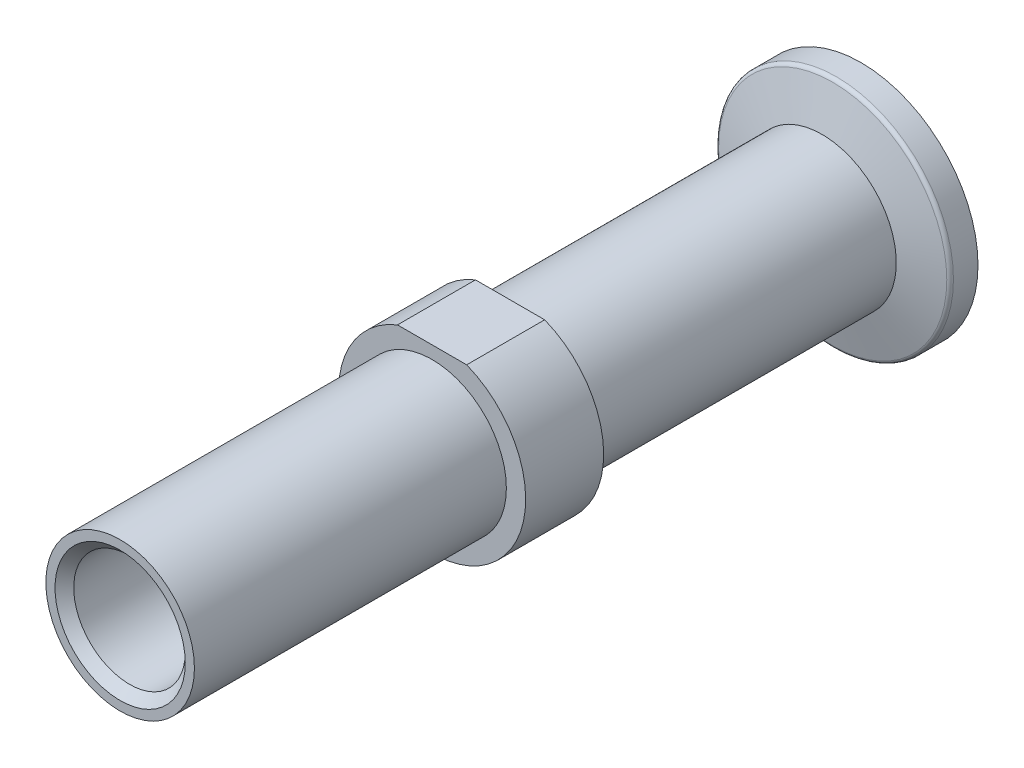
from build123d import *

# Parameters (mm, degrees)
SKETCH1_R           = 12
BOSS_EXTRUDE1_DEPTH = 90
SKETCH3_OUTSIDE_W   = 45.238
SKETCH3_OUTSIDE_H   = 45.238
SKETCH3_OUTSIDE_R   = 9.525
CUT_EXTRUDE1_DEPTH  = 40
SKETCH4_OUTSIDE_W   = 45.238
SKETCH4_OUTSIDE_H   = 45.238
SKETCH4_OUTSIDE_R   = 9.525
CUT_EXTRUDE2_DEPTH  = 40
SKETCH6_R           = 7.15
CUT_EXTRUDE3_DEPTH  = 91
CHAMFER1_SIZE       = 1.2
CUT_EXTRUDE4_DEPTH  = 91


with BuildPart() as part:
    # Sketch1 → Boss-Extrude1 (new body)
    with BuildSketch(Plane.XY):
        Circle(SKETCH1_R)
    extrude(amount=BOSS_EXTRUDE1_DEPTH)

    # Sketch3 outside → Cut-Extrude1 (cut)
    with BuildSketch(Plane.XY.offset(90)):
        Rectangle(SKETCH3_OUTSIDE_W, SKETCH3_OUTSIDE_H)
        Circle(SKETCH3_OUTSIDE_R, mode=Mode.SUBTRACT)
    extrude(amount=-CUT_EXTRUDE1_DEPTH, mode=Mode.SUBTRACT)

    # Sketch4 outside → Cut-Extrude2 (cut)
    with BuildSketch(Plane(origin=(0, 0, 0), x_dir=(-1, 0, 0), z_dir=(0, 0, -1))):
        Rectangle(SKETCH4_OUTSIDE_W, SKETCH4_OUTSIDE_H)
        Circle(SKETCH4_OUTSIDE_R, mode=Mode.SUBTRACT)
    extrude(amount=-CUT_EXTRUDE2_DEPTH, mode=Mode.SUBTRACT)

    # Sketch6 → Cut-Extrude3 (cut, through all)
    with BuildSketch(Plane.XY.offset(90)):
        Circle(SKETCH6_R)
    extrude(amount=-CUT_EXTRUDE3_DEPTH, mode=Mode.SUBTRACT)

    # Chamfer1
    chamfer1_edges = [part.edges().sort_by_distance(p)[0] for p in [
        (-7.15, 0, 90),
    ]]
    chamfer(chamfer1_edges, length=CHAMFER1_SIZE)

    # Sketch7 → Cut-Extrude4 (cut, through all)
    with BuildSketch(Plane(origin=(0, 0, 0), x_dir=(-1, 0, 0), z_dir=(0, 0, -1))):
        Polygon((0, 11.15), (-4.435932822, 11.15), (-4.435932822, 13.87296042), (4.435932822, 13.87296042), (4.435932822, 11.15), align=None)
    extrude(amount=-CUT_EXTRUDE4_DEPTH, mode=Mode.SUBTRACT)

    # Sketch10 → Revolve1 (revolve)
    with BuildSketch(Plane(origin=(0, 0, 0), x_dir=(1, 0, 0), z_dir=(0, 1, 0))):
        with BuildLine():
            Line((9.525, 0), (14.629409523, 1.367722409))
            ThreePointArc((14.629409523, 1.367722409), (14.89667667, 1.546304608), (15, 1.850685323))
            Line((15, 1.850685323), (15, 5))
            Line((15, 5), (9, 5))
            Line((9, 5), (9, 2.5))
            Line((9, 2.5), (7.15, 2.5))
            Line((7.15, 2.5), (7.15, 0))
            Line((7.15, 0), (9.525, 0))
        make_face()
    revolve(axis=Axis((0, 0, 1.6), (0, 0, -1)))


solid = part.part
